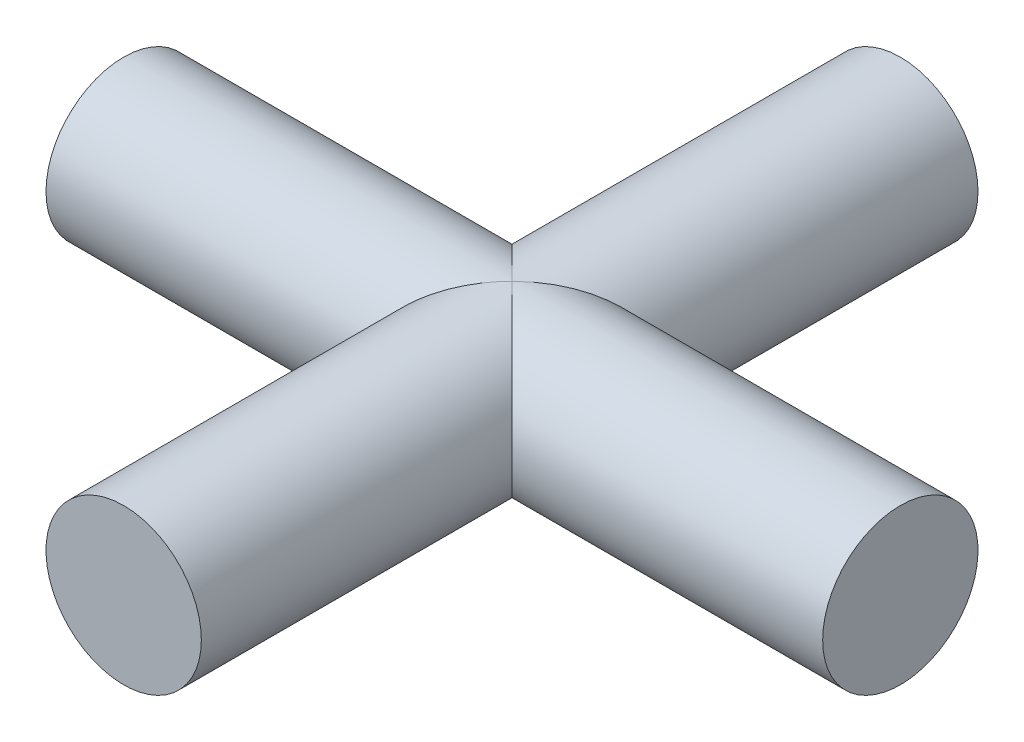
from build123d import *

# Parameters (mm, degrees)
SKETCH1_R           = 6.35
BOSS_EXTRUDE1_DEPTH = 63.5
CIRPATTERN1_COUNT   = 2
CIRPATTERN1_ANGLE   = 90


with BuildPart() as part:
    # Sketch1 → Boss-Extrude1 (new body)
    with BuildSketch(Plane.XY):
        Circle(SKETCH1_R)
    boss_extrude1 = extrude(amount=BOSS_EXTRUDE1_DEPTH)

    # CirPattern1: Boss-Extrude1 ×2 about axis
    cirpattern1_axis = Axis((0, 6.35, 31.75), (0, -1, 0))
    for i in range(1, CIRPATTERN1_COUNT):
        add(boss_extrude1.rotate(cirpattern1_axis, i * CIRPATTERN1_ANGLE / (CIRPATTERN1_COUNT - 1)))


solid = part.part
